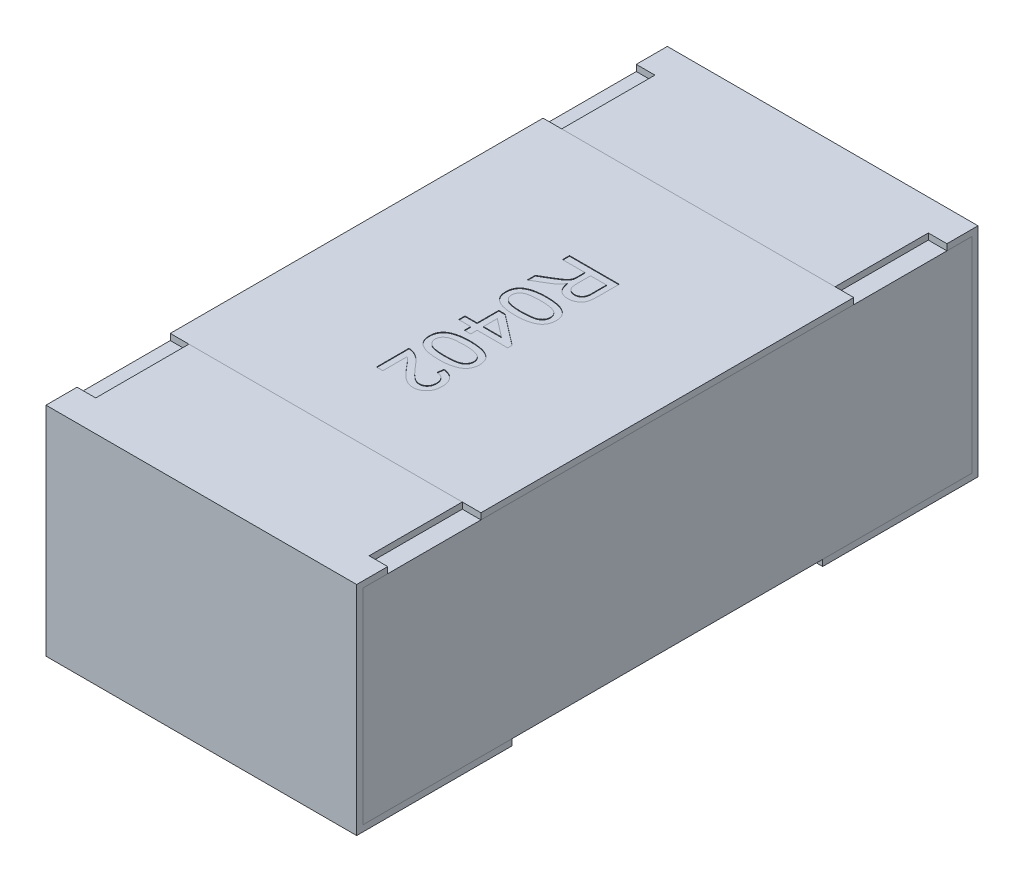
from build123d import *

# Parameters (mm, degrees)
BOSS_EXTRUDE2_DEPTH   = 0.25
BOSS_EXTRUDE2_2_DEPTH = 0.25
BOSS_EXTRUDE3_START   = -0.25
SKETCH5_W             = 0.98
SKETCH5_H             = 0.33
BOSS_EXTRUDE3_DEPTH   = 0.5
SKETCH6_W             = 0.03
SKETCH6_H             = 0.15
CUT_EXTRUDE1_DEPTH    = 0.01
SKETCH7_W             = 0.5
SKETCH7_H             = 0.6
BOSS_EXTRUDE4_DEPTH   = 0.01
TEXT0402_DEPTH        = 0.001


with BuildPart() as part:
    # Sketch4 → Boss-Extrude2 (new, symmetric)
    with BuildSketch(Plane(origin=(0, 0, 0), x_dir=(0, 0, -1), z_dir=(1, 0, 0))):
        Polygon((-0.5, 0.175), (-0.5, -0.175), (-0.25, -0.175), (-0.25, -0.165), (-0.49, -0.165), (-0.49, 0.165), (-0.3, 0.165), (-0.3, 0.175), align=None)
    extrude(amount=BOSS_EXTRUDE2_DEPTH, both=True)


with BuildPart() as body_2:
    # Sketch4 → Boss-Extrude2 2 (new, symmetric)
    with BuildSketch(Plane(origin=(0, 0, 0), x_dir=(0, 0, -1), z_dir=(1, 0, 0))):
        Polygon((0.3, 0.175), (0.5, 0.175), (0.5, -0.175), (0.25, -0.175), (0.25, -0.165), (0.49, -0.165), (0.49, 0.165), (0.3, 0.165), align=None)
    extrude(amount=BOSS_EXTRUDE2_2_DEPTH, both=True)


with BuildPart() as body_3:
    # Sketch5 → Boss-Extrude3 (new body)
    with BuildSketch(Plane(origin=(0, 0, 0), x_dir=(0, 0, -1), z_dir=(1, 0, 0)).offset(BOSS_EXTRUDE3_START)):
        Rectangle(SKETCH5_W, SKETCH5_H)
    extrude(amount=BOSS_EXTRUDE3_DEPTH)


with BuildPart() as cut_extrude1_tool:
    # Sketch6 → Cut-Extrude1 (new body)
    with BuildSketch(Plane(origin=(0, 0.175, 0), x_dir=(1, 0, 0), z_dir=(0, 1, 0))):
        with Locations((-0.235, 0.375)):
            Rectangle(SKETCH6_W, SKETCH6_H)
        with Locations((0.235, 0.375)):
            Rectangle(SKETCH6_W, SKETCH6_H)
        with Locations((0.235, -0.375)):
            Rectangle(SKETCH6_W, SKETCH6_H)
        with Locations((-0.235, -0.375)):
            Rectangle(SKETCH6_W, SKETCH6_H)
    extrude(amount=-CUT_EXTRUDE1_DEPTH)


with BuildPart() as part_1:
    add(part.part)

    # Cut-Extrude1: cut by cut_extrude1_tool
    add(cut_extrude1_tool.part, mode=Mode.SUBTRACT)


with BuildPart() as body_2_1:
    add(body_2.part)

    # Cut-Extrude1: cut by cut_extrude1_tool
    add(cut_extrude1_tool.part, mode=Mode.SUBTRACT)


with BuildPart() as body_4:
    # Sketch7 → Boss-Extrude4 (new body)
    with BuildSketch(Plane(origin=(0, 0.165, 0), x_dir=(1, 0, 0), z_dir=(0, 1, 0))):
        Rectangle(SKETCH7_W, SKETCH7_H)
    extrude(amount=BOSS_EXTRUDE4_DEPTH)

    # Sketch9 → TEXT0402 (cut)
    with BuildSketch(Plane(origin=(0, 0.175, 0), x_dir=(1, 0, 0), z_dir=(0, 1, 0))):
        with BuildLine():
            Line((-0.037185869, 0.129759038), (0.042814131, 0.129759038))
            Line((0.042814131, 0.129759038), (0.042814131, 0.095047499))
            add(Edge.make_bspline(
                [(0.042814131, 0.095047499), (0.042807757, 0.094230145), (0.042795421, 0.092648251), (0.042707271, 0.090354242), (0.042519996, 0.088218074), (0.042310832, 0.086226284), (0.042001999, 0.08438228), (0.041639681, 0.082685183), (0.041211464, 0.081141502), (0.040705294, 0.079739491), (0.040132823, 0.078438629), (0.039426111, 0.077233152), (0.038652982, 0.076071394), (0.037737323, 0.074999313), (0.036752741, 0.073969981), (0.035650564, 0.073018571), (0.034446357, 0.072140442), (0.032724772, 0.071056909), (0.030420255, 0.069916785), (0.027486264, 0.068943692), (0.024410733, 0.068321545), (0.022309647, 0.068254561), (0.021243618, 0.068220576)],
                knots=[0, 0, 0, 0, 1.242122331, 2.403982386, 3.487329914, 4.500326623, 5.446523787, 6.327028739, 7.136568587, 7.878666205, 8.590811102, 9.292609518, 9.999600102, 10.708452415, 11.431798422, 12.162621657, 12.917616336, 13.694634159, 15.252079616, 16.810286496, 18.381632726, 20, 20, 20, 20], degree=3))
            add(Edge.make_bspline(
                [(0.021243618, 0.068220576), (0.020559285, 0.068236231), (0.019207681, 0.06826715), (0.017220459, 0.06850399), (0.015321757, 0.068932543), (0.013494907, 0.069482048), (0.011765933, 0.070234263), (0.010099001, 0.071105278), (0.008541837, 0.072185844), (0.007042594, 0.073392431), (0.005668191, 0.074795172), (0.004400155, 0.076356647), (0.003304604, 0.078116156), (0.002320056, 0.08004132), (0.001458509, 0.082135633), (0.000734129, 0.084413022), (0.000167014, 0.086865423), (-0.000117065, 0.088566102), (-0.000262792, 0.089438525)],
                knots=[0, 0, 0, 0, 0.98268397, 1.940868231, 2.867803148, 3.77529712, 4.675825539, 5.571570676, 6.471608834, 7.392971743, 8.331421822, 9.286283743, 10.275919943, 11.301762849, 12.388744527, 13.524158817, 14.729930953, 16, 16, 16, 16], degree=3))
            add(Edge.make_bspline(
                [(-0.000262792, 0.089438525), (-0.000586875, 0.088793666), (-0.001200248, 0.087573178), (-0.002184972, 0.085889726), (-0.003159468, 0.084444114), (-0.003872054, 0.083610288), (-0.0042051, 0.083220576)],
                knots=[0, 0, 0, 0, 1.172410807, 2.218954047, 3.167579294, 4, 4, 4, 4], degree=3))
            add(Edge.make_bspline(
                [(-0.0042051, 0.083220576), (-0.004944913, 0.082463563), (-0.006462147, 0.080911054), (-0.009070408, 0.078792452), (-0.011938748, 0.076696122), (-0.01402896, 0.075437528), (-0.015102536, 0.074791089)],
                knots=[0, 0, 0, 0, 0.918170575, 1.883016652, 2.912673989, 4, 4, 4, 4], degree=3))
            Line((-0.015102536, 0.074791089), (-0.037185869, 0.061666089))
            Line((-0.037185869, 0.061666089), (-0.037185869, 0.074598781))
            Line((-0.037185869, 0.074598781), (-0.020294844, 0.08456673))
            add(Edge.make_bspline(
                [(-0.020294844, 0.08456673), (-0.019702212, 0.084925142), (-0.018553788, 0.085619686), (-0.016876408, 0.086622688), (-0.015332704, 0.087606988), (-0.013875892, 0.088516927), (-0.012543849, 0.089401179), (-0.011296838, 0.090210089), (-0.010184154, 0.091005891), (-0.008844053, 0.09193142), (-0.007385457, 0.093047278), (-0.005896437, 0.094358222), (-0.004680613, 0.095574636), (-0.003506064, 0.097096535), (-0.002411623, 0.098985005), (-0.001902998, 0.100586908), (-0.001657023, 0.101361602)],
                knots=[0, 0, 0, 0, 1.130769053, 2.191244754, 3.190605808, 4.119719489, 4.995392299, 5.800890497, 6.546104885, 7.228445539, 8.4599972, 9.541354885, 10.466489475, 11.262010607, 12.675885558, 14, 14, 14, 14], degree=3))
            add(Edge.make_bspline(
                [(-0.001657023, 0.101361602), (-0.001598383, 0.101686779), (-0.001464505, 0.102429167), (-0.001377069, 0.103689742), (-0.001284267, 0.105217082), (-0.001286971, 0.106323972), (-0.001288433, 0.106922499)],
                knots=[0, 0, 0, 0, 0.709978628, 1.620902492, 2.713552433, 4, 4, 4, 4], degree=3))
            Line((-0.001288433, 0.106922499), (-0.001288433, 0.118476986))
            Line((-0.001288433, 0.118476986), (-0.037185869, 0.118476986))
            Line((-0.037185869, 0.118476986), (-0.037185869, 0.129759038))
        make_face()
        with BuildLine():
            Line((0.007942336, 0.118476986), (0.007942336, 0.097050704))
            add(Edge.make_bspline(
                [(0.007942336, 0.097050704), (0.007959213, 0.095976324), (0.007990764, 0.093967869), (0.008258282, 0.091159156), (0.008688061, 0.088761157), (0.009304883, 0.086729113), (0.010165118, 0.085022819), (0.01123393, 0.083556952), (0.012534386, 0.082309912), (0.01402974, 0.081290736), (0.015661327, 0.080488008), (0.017387323, 0.079940017), (0.019170391, 0.079558235), (0.020386875, 0.079521327), (0.021003233, 0.079502627)],
                knots=[0, 0, 0, 0, 1.545806995, 2.889741191, 4.055176196, 5.047087691, 5.934047151, 6.79198357, 7.645535072, 8.5133672, 9.386595861, 10.252007348, 11.114340652, 12, 12, 12, 12], degree=3))
            add(Edge.make_bspline(
                [(0.021003233, 0.079502627), (0.021452285, 0.079517518), (0.022331845, 0.079546683), (0.023622795, 0.079699578), (0.024849497, 0.079996843), (0.026018433, 0.08038938), (0.027121043, 0.08091389), (0.028165871, 0.081536986), (0.029147126, 0.082280532), (0.030067797, 0.08313222), (0.030905517, 0.084110114), (0.031628288, 0.085227099), (0.032242488, 0.086474364), (0.032729958, 0.087853361), (0.033119854, 0.089359744), (0.03337924, 0.09100209), (0.03356693, 0.092772887), (0.033577782, 0.093999947), (0.033583361, 0.094630833)],
                knots=[0, 0, 0, 0, 0.965208469, 1.890559848, 2.786986821, 3.67262109, 4.535197034, 5.405224191, 6.282113641, 7.175449223, 8.095446547, 9.040936516, 10.026471658, 11.075712529, 12.17809725, 13.364958037, 14.645208957, 16, 16, 16, 16], degree=3))
            Line((0.033583361, 0.094630833), (0.033583361, 0.118476986))
            Line((0.033583361, 0.118476986), (0.007942336, 0.118476986))
        make_face(mode=Mode.SUBTRACT)
        with BuildLine():
            add(Edge.make_bspline(
                [(0.002269259, 0.053861602), (0.003412532, 0.053851268), (0.005651723, 0.05383103), (0.008928063, 0.053705496), (0.012039466, 0.053486324), (0.014983232, 0.053159162), (0.017766003, 0.052771735), (0.02038382, 0.052268098), (0.022842508, 0.051701367), (0.025139677, 0.051021622), (0.027294474, 0.050274023), (0.029305545, 0.049428595), (0.031160993, 0.048469013), (0.032911208, 0.047481808), (0.034474204, 0.046332448), (0.035948981, 0.045166859), (0.037251357, 0.04386583), (0.038423961, 0.042491238), (0.039458388, 0.041020301), (0.04035106, 0.03946147), (0.041139201, 0.037820564), (0.041732519, 0.036066357), (0.042216198, 0.034235254), (0.042571998, 0.032313164), (0.042781754, 0.030297966), (0.042803217, 0.028920862), (0.042814131, 0.028220576)],
                knots=[0, 0, 0, 0, 1.514715004, 2.966688829, 4.343277319, 5.646155648, 6.890271291, 8.064567311, 9.176982507, 10.231801866, 11.236819303, 12.197732759, 13.118802951, 14.00370591, 14.856056722, 15.686168072, 16.491905873, 17.290274347, 18.077650358, 18.870352107, 19.668187111, 20.485160842, 21.319455353, 22.17593919, 23.072426909, 24, 24, 24, 24], degree=3))
            add(Edge.make_bspline(
                [(0.042814131, 0.028220576), (0.042783898, 0.027193184), (0.042724506, 0.025174829), (0.042240929, 0.022227709), (0.04141165, 0.01945143), (0.040301648, 0.016846429), (0.038865772, 0.014469032), (0.037165145, 0.012319644), (0.035128565, 0.01048511), (0.032822867, 0.00890483), (0.030243471, 0.00754974), (0.027414671, 0.006337557), (0.024324473, 0.005250721), (0.02156615, 0.004455205), (0.019181034, 0.003897477), (0.017210138, 0.003557917), (0.015090059, 0.003244405), (0.01281572, 0.003022183), (0.010397751, 0.002796054), (0.007825607, 0.002684412), (0.005101037, 0.002599212), (0.00323088, 0.002586227), (0.002269259, 0.00257955)],
                knots=[0, 0, 0, 0, 1.134508601, 2.228787654, 3.287419779, 4.328790846, 5.347871456, 6.346850563, 7.345149742, 8.363256079, 9.427154287, 10.558404831, 11.760335901, 13.043439251, 13.7276639, 14.464993199, 15.251939769, 16.09452972, 16.988861801, 17.934185368, 18.937772297, 20, 20, 20, 20], degree=3))
            add(Edge.make_bspline(
                [(0.002269259, 0.00257955), (0.001131347, 0.002590019), (-0.001091789, 0.002610472), (-0.004341733, 0.002733451), (-0.007430101, 0.002962981), (-0.010360662, 0.003258763), (-0.013136131, 0.003656996), (-0.015749717, 0.004154742), (-0.018204625, 0.00472964), (-0.020503331, 0.005380215), (-0.022648999, 0.006137112), (-0.024651898, 0.006990792), (-0.026531652, 0.007906189), (-0.028253253, 0.008944498), (-0.029845201, 0.010050358), (-0.031312506, 0.011234102), (-0.032634314, 0.012520249), (-0.033803065, 0.013907672), (-0.034856095, 0.015368107), (-0.035756883, 0.01693099), (-0.036508367, 0.018592663), (-0.037136448, 0.020338317), (-0.037613777, 0.022179539), (-0.037968181, 0.024106735), (-0.038179863, 0.026132479), (-0.038200816, 0.027514941), (-0.03821151, 0.028220576)],
                knots=[0, 0, 0, 0, 1.50892112, 2.947974422, 4.311604492, 5.614840882, 6.853004102, 8.028299315, 9.14166105, 10.195403725, 11.194594867, 12.156325951, 13.08133133, 13.964490992, 14.819271038, 15.650088719, 16.461567135, 17.260614929, 18.05275699, 18.846133239, 19.648095618, 20.468123593, 21.303127994, 22.167306962, 23.06455749, 24, 24, 24, 24], degree=3))
            add(Edge.make_bspline(
                [(-0.03821151, 0.028220576), (-0.03818512, 0.029145725), (-0.038133667, 0.030949512), (-0.037784075, 0.033583809), (-0.037168777, 0.036056237), (-0.036343574, 0.038387651), (-0.035239819, 0.040551843), (-0.033896885, 0.042559147), (-0.032346017, 0.044449899), (-0.031122418, 0.045538331), (-0.030503177, 0.046089166)],
                knots=[0, 0, 0, 0, 1.10322584, 2.150986741, 3.161425019, 4.136713905, 5.093944212, 6.049774532, 7.013026876, 8, 8, 8, 8], degree=3))
            add(Edge.make_bspline(
                [(-0.030503177, 0.046089166), (-0.029588588, 0.04672319), (-0.027702667, 0.048030575), (-0.024486996, 0.049560755), (-0.020946993, 0.050925703), (-0.017013205, 0.051996937), (-0.01271694, 0.05283598), (-0.008049767, 0.053441979), (-0.003013703, 0.053784914), (0.000468518, 0.053835462), (0.002269259, 0.053861602)],
                knots=[0, 0, 0, 0, 0.779365345, 1.607084704, 2.489375761, 3.438383567, 4.461919411, 5.557722155, 6.737039282, 8, 8, 8, 8], degree=3))
        make_face()
        with BuildLine():
            add(Edge.make_bspline(
                [(0.00230131, 0.043605192), (0.000762619, 0.043595008), (-0.002182776, 0.043575514), (-0.006390781, 0.043371848), (-0.010186975, 0.043021247), (-0.013566104, 0.042557728), (-0.016532737, 0.041945696), (-0.019079315, 0.041177218), (-0.021236403, 0.04031096), (-0.022977265, 0.039238982), (-0.024396322, 0.038065285), (-0.025616756, 0.036853523), (-0.026654097, 0.035575187), (-0.027519028, 0.034238618), (-0.028173897, 0.03282308), (-0.028648548, 0.031344049), (-0.028921702, 0.029801206), (-0.028960949, 0.028750459), (-0.028980741, 0.028220576)],
                knots=[0, 0, 0, 0, 1.89448813, 3.626469325, 5.185477471, 6.587276848, 7.82441448, 8.910550357, 9.859733512, 10.6775885, 11.416198291, 12.123144072, 12.791880183, 13.439617036, 14.078171869, 14.70637855, 15.347637704, 16, 16, 16, 16], degree=3))
            add(Edge.make_bspline(
                [(-0.028980741, 0.028220576), (-0.028960517, 0.027690826), (-0.028920412, 0.026640343), (-0.028653281, 0.025093934), (-0.028154196, 0.023620658), (-0.02750164, 0.02220723), (-0.026656423, 0.020860947), (-0.025615164, 0.019588889), (-0.024395454, 0.018370744), (-0.022959903, 0.017202319), (-0.021210993, 0.016138508), (-0.019055662, 0.015256), (-0.016504624, 0.014499498), (-0.013539502, 0.013884108), (-0.010165717, 0.013418677), (-0.006380051, 0.013070195), (-0.00217746, 0.012865167), (0.000762612, 0.012845995), (0.00230131, 0.012835961)],
                knots=[0, 0, 0, 0, 0.652509534, 1.29391342, 1.924290653, 2.562989607, 3.207355802, 3.876242846, 4.583348185, 5.32723334, 6.150888545, 7.094226006, 8.186903555, 9.424320409, 10.81992305, 12.379283064, 14.105084285, 16, 16, 16, 16], degree=3))
            add(Edge.make_bspline(
                [(0.00230131, 0.012835961), (0.003807993, 0.012845673), (0.00669474, 0.012864282), (0.010821676, 0.0130746), (0.014554158, 0.013404179), (0.017895599, 0.013855016), (0.020842463, 0.014454101), (0.023400735, 0.015180941), (0.025565851, 0.016046373), (0.027356803, 0.017077542), (0.028835174, 0.018220869), (0.030089877, 0.019435624), (0.031189416, 0.0206983), (0.032050378, 0.022081053), (0.03275649, 0.023525101), (0.033229185, 0.025061398), (0.033532557, 0.026670109), (0.033566179, 0.027770434), (0.033583361, 0.028332756)],
                knots=[0, 0, 0, 0, 1.850145643, 3.544809038, 5.072983816, 6.450691362, 7.683229814, 8.76276662, 9.712991103, 10.538891656, 11.292051756, 12.001912283, 12.681449089, 13.342071824, 13.996410874, 14.649960216, 15.310061595, 16, 16, 16, 16], degree=3))
            add(Edge.make_bspline(
                [(0.033583361, 0.028332756), (0.033569455, 0.028862605), (0.033542033, 0.0299074), (0.033280293, 0.031437117), (0.032842605, 0.032886812), (0.032249714, 0.034273093), (0.031451799, 0.035561353), (0.030520178, 0.036802681), (0.029385101, 0.037938939), (0.028536535, 0.038623637), (0.028102592, 0.038973781)],
                knots=[0, 0, 0, 0, 1.021318143, 2.013908504, 2.982026795, 3.937174072, 4.91255697, 5.897578595, 6.924855925, 8, 8, 8, 8], degree=3))
            add(Edge.make_bspline(
                [(0.028102592, 0.038973781), (0.027465265, 0.039354981), (0.026119363, 0.040159995), (0.023780131, 0.041060758), (0.021106834, 0.041856457), (0.018058341, 0.042511581), (0.014639882, 0.042985517), (0.010855427, 0.043359671), (0.006699691, 0.04355403), (0.003807888, 0.043587667), (0.00230131, 0.043605192)],
                knots=[0, 0, 0, 0, 0.671104906, 1.417232262, 2.260109084, 3.195198885, 4.23592645, 5.382417421, 6.636286093, 8, 8, 8, 8], degree=3))
        make_face(mode=Mode.SUBTRACT)
        Polygon((-0.037185869, -0.038446091), (-0.01769869, -0.038446091), (-0.01769869, -0.003574296), (-0.00744228, -0.003574296), (0.04178849, -0.041523014), (0.04178849, -0.048702501), (-0.00744228, -0.048702501), (-0.00744228, -0.058958911), (-0.01769869, -0.058958911), (-0.01769869, -0.048702501), (-0.037185869, -0.048702501), align=None)
        Polygon((-0.00744228, -0.038446091), (0.021371823, -0.038446091), (-0.00744228, -0.016234552), align=None, mode=Mode.SUBTRACT)
        with BuildLine():
            add(Edge.make_bspline(
                [(0.002269259, -0.069215321), (0.003412532, -0.069225655), (0.005651723, -0.069245893), (0.008928063, -0.069371427), (0.012039466, -0.069590599), (0.014983232, -0.069917761), (0.017766003, -0.070305188), (0.02038382, -0.070808825), (0.022842508, -0.071375556), (0.025139677, -0.072055301), (0.027294474, -0.0728029), (0.029305545, -0.073648329), (0.031160993, -0.07460791), (0.032911208, -0.075595115), (0.034474204, -0.076744475), (0.035948981, -0.077910064), (0.037251357, -0.079211093), (0.038423961, -0.080585686), (0.039458388, -0.082056622), (0.04035106, -0.083615453), (0.041139201, -0.085256359), (0.041732519, -0.087010566), (0.042216198, -0.088841669), (0.042571998, -0.090763759), (0.042781754, -0.092778957), (0.042803217, -0.094156061), (0.042814131, -0.094856347)],
                knots=[0, 0, 0, 0, 1.514715004, 2.966688829, 4.343277319, 5.646155648, 6.890271291, 8.064567311, 9.176982507, 10.231801866, 11.236819303, 12.197732759, 13.118802951, 14.00370591, 14.856056722, 15.686168072, 16.491905873, 17.290274347, 18.077650358, 18.870352107, 19.668187111, 20.485160842, 21.319455353, 22.17593919, 23.072426909, 24, 24, 24, 24], degree=3))
            add(Edge.make_bspline(
                [(0.042814131, -0.094856347), (0.042783898, -0.09588374), (0.042724506, -0.097902094), (0.042240929, -0.100849214), (0.04141165, -0.103625493), (0.040301648, -0.106230494), (0.038865772, -0.108607891), (0.037165145, -0.110757279), (0.035128565, -0.112591813), (0.032822867, -0.114172093), (0.030243471, -0.115527183), (0.027414671, -0.116739367), (0.024324473, -0.117826202), (0.02156615, -0.118621718), (0.019181034, -0.119179446), (0.017210138, -0.119519006), (0.015090059, -0.119832518), (0.01281572, -0.12005474), (0.010397751, -0.120280869), (0.007825607, -0.120392511), (0.005101037, -0.120477711), (0.00323088, -0.120490696), (0.002269259, -0.120497373)],
                knots=[0, 0, 0, 0, 1.134508601, 2.228787654, 3.287419779, 4.328790846, 5.347871456, 6.346850563, 7.345149742, 8.363256079, 9.427154287, 10.558404831, 11.760335901, 13.043439251, 13.7276639, 14.464993199, 15.251939769, 16.09452972, 16.988861801, 17.934185368, 18.937772297, 20, 20, 20, 20], degree=3))
            add(Edge.make_bspline(
                [(0.002269259, -0.120497373), (0.001131347, -0.120486904), (-0.001091789, -0.120466451), (-0.004341733, -0.120343472), (-0.007430101, -0.120113943), (-0.010360662, -0.11981816), (-0.013136131, -0.119419927), (-0.015749717, -0.118922181), (-0.018204625, -0.118347283), (-0.020503331, -0.117696708), (-0.022648999, -0.116939811), (-0.024651898, -0.116086131), (-0.026531652, -0.115170734), (-0.028253253, -0.114132426), (-0.029845201, -0.113026565), (-0.031312506, -0.111842821), (-0.032634314, -0.110556674), (-0.033803065, -0.109169252), (-0.034856095, -0.107708816), (-0.035756883, -0.106145933), (-0.036508367, -0.10448426), (-0.037136448, -0.102738606), (-0.037613777, -0.100897384), (-0.037968181, -0.098970188), (-0.038179863, -0.096944444), (-0.038200816, -0.095561983), (-0.03821151, -0.094856347)],
                knots=[0, 0, 0, 0, 1.50892112, 2.947974422, 4.311604492, 5.614840882, 6.853004102, 8.028299315, 9.14166105, 10.195403725, 11.194594867, 12.156325951, 13.08133133, 13.964490992, 14.819271038, 15.650088719, 16.461567135, 17.260614929, 18.05275699, 18.846133239, 19.648095618, 20.468123593, 21.303127994, 22.167306962, 23.06455749, 24, 24, 24, 24], degree=3))
            add(Edge.make_bspline(
                [(-0.03821151, -0.094856347), (-0.03818512, -0.093931198), (-0.038133667, -0.092127411), (-0.037784075, -0.089493114), (-0.037168777, -0.087020686), (-0.036343574, -0.084689273), (-0.035239819, -0.08252508), (-0.033896885, -0.080517776), (-0.032346017, -0.078627024), (-0.031122418, -0.077538592), (-0.030503177, -0.076987757)],
                knots=[0, 0, 0, 0, 1.10322584, 2.150986741, 3.161425019, 4.136713905, 5.093944212, 6.049774532, 7.013026876, 8, 8, 8, 8], degree=3))
            add(Edge.make_bspline(
                [(-0.030503177, -0.076987757), (-0.029588588, -0.076353733), (-0.027702667, -0.075046349), (-0.024486996, -0.073516168), (-0.020946993, -0.07215122), (-0.017013205, -0.071079986), (-0.01271694, -0.070240943), (-0.008049767, -0.069634944), (-0.003013703, -0.069292009), (0.000468518, -0.069241461), (0.002269259, -0.069215321)],
                knots=[0, 0, 0, 0, 0.779365345, 1.607084704, 2.489375761, 3.438383567, 4.461919411, 5.557722155, 6.737039282, 8, 8, 8, 8], degree=3))
        make_face()
        with BuildLine():
            add(Edge.make_bspline(
                [(0.00230131, -0.079471732), (0.000762619, -0.079481915), (-0.002182776, -0.079501409), (-0.006390781, -0.079705075), (-0.010186975, -0.080055677), (-0.013566104, -0.080519195), (-0.016532737, -0.081131227), (-0.019079315, -0.081899705), (-0.021236403, -0.082765963), (-0.022977265, -0.083837941), (-0.024396322, -0.085011638), (-0.025616756, -0.086223401), (-0.026654097, -0.087501736), (-0.027519028, -0.088838305), (-0.028173897, -0.090253843), (-0.028648548, -0.091732874), (-0.028921702, -0.093275718), (-0.028960949, -0.094326464), (-0.028980741, -0.094856347)],
                knots=[0, 0, 0, 0, 1.89448813, 3.626469325, 5.185477471, 6.587276848, 7.82441448, 8.910550357, 9.859733512, 10.6775885, 11.416198291, 12.123144072, 12.791880183, 13.439617036, 14.078171869, 14.70637855, 15.347637704, 16, 16, 16, 16], degree=3))
            add(Edge.make_bspline(
                [(-0.028980741, -0.094856347), (-0.028960517, -0.095386097), (-0.028920412, -0.096436581), (-0.028653281, -0.097982989), (-0.028154196, -0.099456265), (-0.02750164, -0.100869693), (-0.026656423, -0.102215976), (-0.025615164, -0.103488034), (-0.024395454, -0.104706179), (-0.022959903, -0.105874604), (-0.021210993, -0.106938415), (-0.019055662, -0.107820923), (-0.016504624, -0.108577425), (-0.013539502, -0.109192815), (-0.010165717, -0.109658246), (-0.006380051, -0.110006728), (-0.00217746, -0.110211756), (0.000762612, -0.110230928), (0.00230131, -0.110240962)],
                knots=[0, 0, 0, 0, 0.652509534, 1.29391342, 1.924290653, 2.562989607, 3.207355802, 3.876242846, 4.583348185, 5.32723334, 6.150888545, 7.094226006, 8.186903555, 9.424320409, 10.81992305, 12.379283064, 14.105084285, 16, 16, 16, 16], degree=3))
            add(Edge.make_bspline(
                [(0.00230131, -0.110240962), (0.003807993, -0.11023125), (0.00669474, -0.110212641), (0.010821676, -0.110002323), (0.014554158, -0.109672744), (0.017895599, -0.109221907), (0.020842463, -0.108622822), (0.023400735, -0.107895982), (0.025565851, -0.10703055), (0.027356803, -0.105999381), (0.028835174, -0.104856055), (0.030089877, -0.103641299), (0.031189416, -0.102378623), (0.032050378, -0.10099587), (0.03275649, -0.099551822), (0.033229185, -0.098015525), (0.033532557, -0.096406814), (0.033566179, -0.095306489), (0.033583361, -0.094744167)],
                knots=[0, 0, 0, 0, 1.850145643, 3.544809038, 5.072983816, 6.450691362, 7.683229814, 8.76276662, 9.712991103, 10.538891656, 11.292051756, 12.001912283, 12.681449089, 13.342071824, 13.996410874, 14.649960216, 15.310061595, 16, 16, 16, 16], degree=3))
            add(Edge.make_bspline(
                [(0.033583361, -0.094744167), (0.033569455, -0.094214318), (0.033542033, -0.093169523), (0.033280293, -0.091639806), (0.032842605, -0.090190111), (0.032249714, -0.08880383), (0.031451799, -0.08751557), (0.030520178, -0.086274242), (0.029385101, -0.085137984), (0.028536535, -0.084453286), (0.028102592, -0.084103142)],
                knots=[0, 0, 0, 0, 1.021318143, 2.013908504, 2.982026795, 3.937174072, 4.91255697, 5.897578595, 6.924855925, 8, 8, 8, 8], degree=3))
            add(Edge.make_bspline(
                [(0.028102592, -0.084103142), (0.027465265, -0.083721942), (0.026119363, -0.082916928), (0.023780131, -0.082016165), (0.021106834, -0.081220466), (0.018058341, -0.080565342), (0.014639882, -0.080091406), (0.010855427, -0.079717252), (0.006699691, -0.079522893), (0.003807888, -0.079489256), (0.00230131, -0.079471732)],
                knots=[0, 0, 0, 0, 0.671104906, 1.417232262, 2.260109084, 3.195198885, 4.23592645, 5.382417421, 6.636286093, 8, 8, 8, 8], degree=3))
        make_face(mode=Mode.SUBTRACT)
        with BuildLine():
            Line((-0.026929459, -0.181010193), (-0.037185869, -0.181010193))
            Line((-0.037185869, -0.181010193), (-0.037185869, -0.128702501))
            add(Edge.make_bspline(
                [(-0.037185869, -0.128702501), (-0.036576302, -0.12870143), (-0.035359211, -0.128699292), (-0.03355921, -0.128905243), (-0.031783087, -0.129227804), (-0.03064413, -0.129592524), (-0.030070485, -0.129776219)],
                knots=[0, 0, 0, 0, 1.01057331, 2.01775941, 3.001627217, 4, 4, 4, 4], degree=3))
            add(Edge.make_bspline(
                [(-0.030070485, -0.129776219), (-0.02913342, -0.130115956), (-0.027225403, -0.130807718), (-0.024466099, -0.132203877), (-0.021739768, -0.133873354), (-0.0195042, -0.13547108), (-0.01773115, -0.136942588), (-0.016327217, -0.138156043), (-0.01490813, -0.139522976), (-0.013448587, -0.141018468), (-0.011948503, -0.142633443), (-0.010400887, -0.144367838), (-0.008835156, -0.146242793), (-0.007797301, -0.14755168), (-0.007265998, -0.148221732)],
                knots=[0, 0, 0, 0, 1.204749664, 2.453068735, 3.731868309, 5.069624937, 5.772016546, 6.5184395, 7.31363639, 8.154361805, 9.045869205, 9.979533915, 10.965673542, 12, 12, 12, 12], degree=3))
            add(Edge.make_bspline(
                [(-0.007265998, -0.148221732), (-0.006399595, -0.1492511), (-0.004731281, -0.151233214), (-0.002255659, -0.15403227), (4.3097e-05, -0.156588752), (0.002205276, -0.158861951), (0.004209907, -0.16087046), (0.006052449, -0.162618993), (0.00772715, -0.164122597), (0.009294628, -0.165362916), (0.010774763, -0.16640941), (0.012218544, -0.167296222), (0.01365119, -0.168035262), (0.015068167, -0.168650783), (0.016475536, -0.169137608), (0.017877396, -0.169469449), (0.019259838, -0.169694491), (0.02017973, -0.169717007), (0.020634643, -0.169728142)],
                knots=[0, 0, 0, 0, 1.782554561, 3.432421876, 4.950675607, 6.337395053, 7.588547463, 8.709982106, 9.702713005, 10.569305638, 11.356701089, 12.103210377, 12.812277205, 13.490692607, 14.148717897, 14.782152033, 15.397739362, 16, 16, 16, 16], degree=3))
            add(Edge.make_bspline(
                [(0.020634643, -0.169728142), (0.021084249, -0.169717006), (0.02196635, -0.169695158), (0.023257299, -0.169487863), (0.024500514, -0.169199291), (0.025673614, -0.16873276), (0.02681134, -0.168177447), (0.027877736, -0.167465122), (0.028899402, -0.166641116), (0.029849316, -0.165697671), (0.03074074, -0.164667311), (0.031480801, -0.163515644), (0.032153026, -0.162315774), (0.032677609, -0.161028045), (0.03308189, -0.159663925), (0.033363533, -0.158225603), (0.033545618, -0.156709237), (0.03357059, -0.155674191), (0.033583361, -0.155144808)],
                knots=[0, 0, 0, 0, 0.988220144, 1.938834179, 2.870816983, 3.789593262, 4.709270892, 5.651202005, 6.603702613, 7.592551374, 8.593130825, 9.593710277, 10.598146602, 11.615084639, 12.644976104, 13.72352976, 14.835681034, 16, 16, 16, 16], degree=3))
            add(Edge.make_bspline(
                [(0.033583361, -0.155144808), (0.033570568, -0.154588738), (0.033545529, -0.153500468), (0.033363919, -0.151909536), (0.033084806, -0.150399868), (0.032665281, -0.148976849), (0.032116047, -0.147643325), (0.031461416, -0.146389841), (0.030685604, -0.145221192), (0.029784531, -0.144156078), (0.028803002, -0.143169451), (0.027693213, -0.142335968), (0.026513567, -0.14160739), (0.02522661, -0.141032635), (0.023860613, -0.140563903), (0.022395297, -0.140225571), (0.020836948, -0.140040657), (0.019769709, -0.140003525), (0.019224387, -0.139984552)],
                knots=[0, 0, 0, 0, 1.131353863, 2.214142649, 3.254522363, 4.251993147, 5.226998864, 6.184887163, 7.125534989, 8.07474883, 9.020220684, 9.950764588, 10.892228595, 11.83594911, 12.812226535, 13.827427868, 14.889891388, 16, 16, 16, 16], degree=3))
            Line((0.019224387, -0.139984552), (0.020250028, -0.129728142))
            add(Edge.make_bspline(
                [(0.020250028, -0.129728142), (0.021143907, -0.129833068), (0.022882872, -0.130037194), (0.025401339, -0.130545849), (0.027744721, -0.131259201), (0.029943449, -0.132115337), (0.031970626, -0.133180767), (0.033833647, -0.134415929), (0.035541025, -0.13581986), (0.037053053, -0.137417008), (0.038433161, -0.139146244), (0.039594314, -0.141050462), (0.040600437, -0.143085489), (0.04141398, -0.145265808), (0.042037337, -0.147590562), (0.042483041, -0.150056132), (0.042758111, -0.152665308), (0.042795191, -0.154455021), (0.042814131, -0.155369167)],
                knots=[0, 0, 0, 0, 1.130902199, 2.200072888, 3.223843306, 4.206271996, 5.161246612, 6.096017809, 7.01151883, 7.932713564, 8.85544837, 9.78703152, 10.729845199, 11.705020675, 12.706647005, 13.750927778, 14.851223069, 16, 16, 16, 16], degree=3))
            add(Edge.make_bspline(
                [(0.042814131, -0.155369167), (0.042798284, -0.156294248), (0.042767415, -0.158096312), (0.042451747, -0.160722256), (0.041959712, -0.163199726), (0.041275286, -0.165538638), (0.040371374, -0.167726565), (0.039282695, -0.169770998), (0.037990534, -0.171665464), (0.036500545, -0.173384244), (0.03487323, -0.174934223), (0.033135718, -0.176290557), (0.031302059, -0.177430843), (0.029377551, -0.178374016), (0.027349741, -0.179096213), (0.025226235, -0.179598812), (0.023012196, -0.179941892), (0.021501374, -0.179970143), (0.020730797, -0.179984552)],
                knots=[0, 0, 0, 0, 1.195163465, 2.32818547, 3.412777349, 4.456995471, 5.472468761, 6.467096601, 7.445683341, 8.429710765, 9.401551923, 10.346206623, 11.27346832, 12.187474603, 13.111233882, 14.049000595, 15.004916959, 16, 16, 16, 16], degree=3))
            add(Edge.make_bspline(
                [(0.020730797, -0.179984552), (0.019939037, -0.179962922), (0.018353768, -0.179919614), (0.015987259, -0.179568873), (0.013639293, -0.179004288), (0.011291208, -0.178220883), (0.00894096, -0.177130631), (0.006532113, -0.175787899), (0.004082504, -0.174109666), (0.00198447, -0.172518133), (0.000238021, -0.171019663), (-0.001202561, -0.169691448), (-0.002739147, -0.168155161), (-0.004401822, -0.166451654), (-0.006166002, -0.164546036), (-0.008058272, -0.162473034), (-0.010038557, -0.160191473), (-0.011391082, -0.158607319), (-0.012089716, -0.157789039)],
                knots=[0, 0, 0, 0, 0.927016037, 1.85607784, 2.795426669, 3.753038224, 4.749807569, 5.825438141, 6.979408615, 8.224540393, 8.907917664, 9.673913905, 10.518929318, 11.452509573, 12.461825982, 13.560287397, 14.739790317, 16, 16, 16, 16], degree=3))
            add(Edge.make_bspline(
                [(-0.012089716, -0.157789039), (-0.012660157, -0.15708832), (-0.0137479, -0.155752156), (-0.015325006, -0.153851356), (-0.016770562, -0.152148292), (-0.018039997, -0.150605403), (-0.019183921, -0.149274966), (-0.020179152, -0.148128445), (-0.021039688, -0.147177226), (-0.022359865, -0.145727141), (-0.024225926, -0.143876563), (-0.026053388, -0.14252399), (-0.026929459, -0.141875578)],
                knots=[0, 0, 0, 0, 1.24205232, 2.36840259, 3.395101816, 4.312728136, 5.114777656, 5.806942724, 6.399692637, 6.87784234, 8.503262741, 10, 10, 10, 10], degree=3))
            Line((-0.026929459, -0.141875578), (-0.026929459, -0.181010193))
        make_face()
    extrude(amount=-TEXT0402_DEPTH, mode=Mode.SUBTRACT)


solid = Compound([body_3.part, part_1.part, body_2_1.part, body_4.part])
